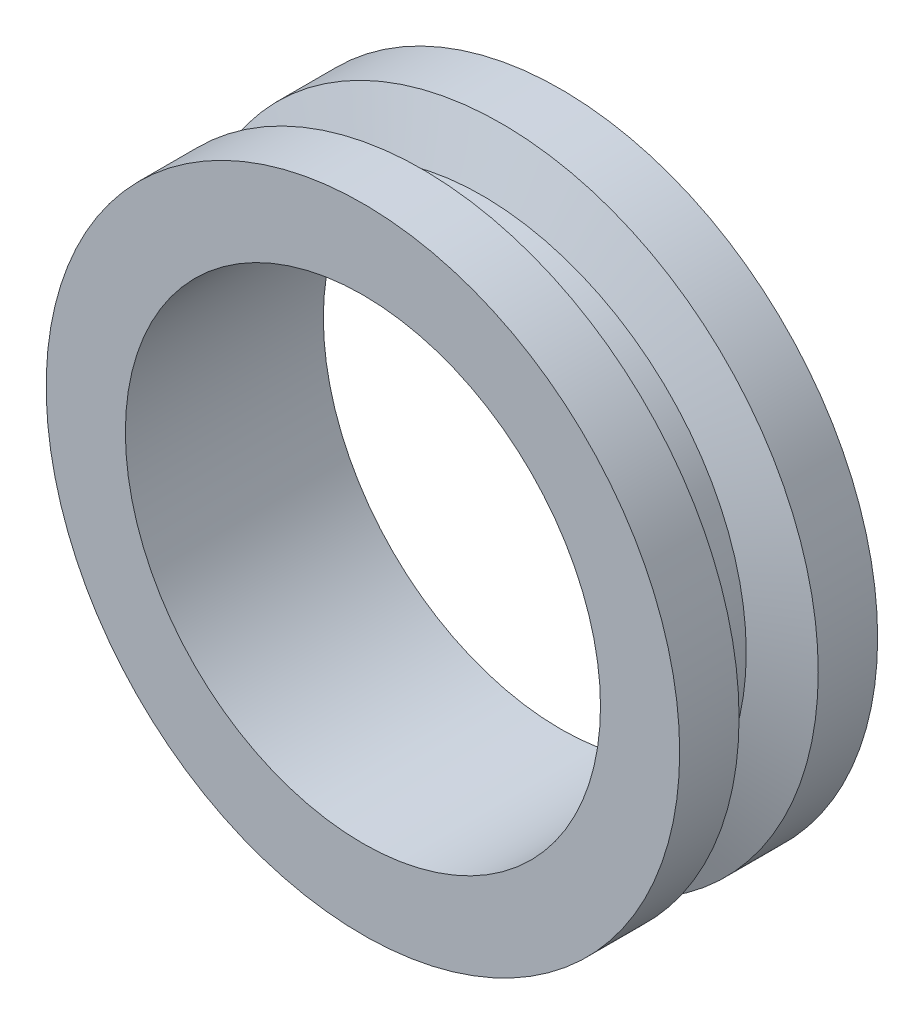
from build123d import *


with BuildPart() as part:
    # Croquis1 → Revolución1 (revolve)
    with BuildSketch(Plane(origin=(0, 0, 0), x_dir=(1, 0, 0), z_dir=(0, 1, 0))):
        Polygon((18, 7.5), (18, -7.5), (24, -7.5), (24, -3), (20, -1.544119063), (20, 1.544119063), (24, 3), (24, 7.5), align=None)
    revolve(axis=Axis((0, 0, 7.5), (0, 0, -1)))


solid = part.part
